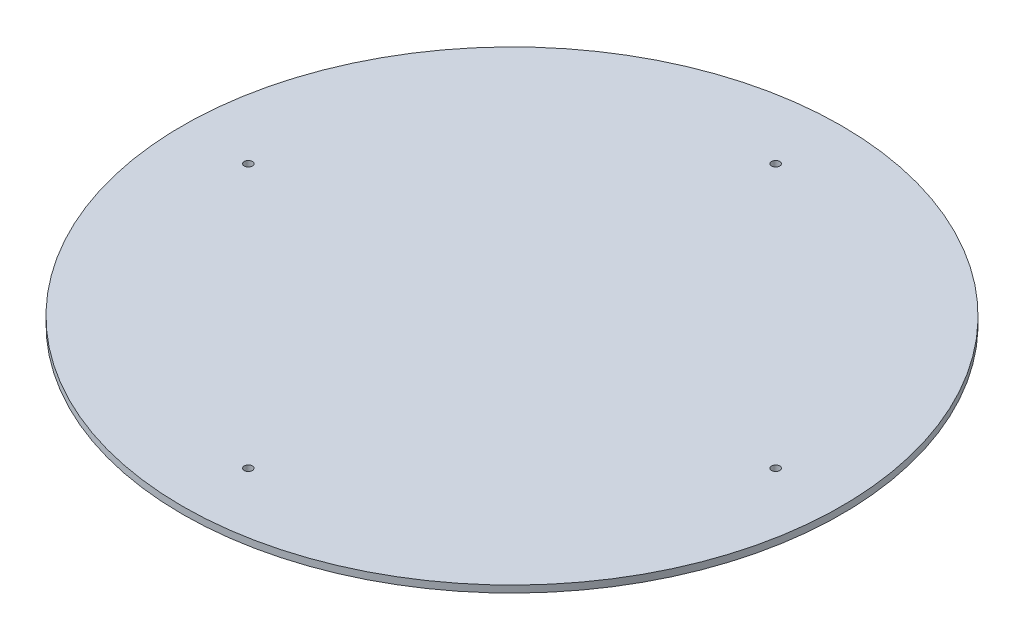
from build123d import *

# Parameters (mm, degrees)
TAPA_R                  = 285
SALIENTE_EXTRUIR1_DEPTH = 6
CROQUIS2_R              = 3.5
CORTAR_EXTRUIR4_DEPTH   = 7


with BuildPart() as part:
    # Tapa → Saliente-Extruir1 (new body)
    with BuildSketch(Plane(origin=(0, 0, 0), x_dir=(1, 0, 0), z_dir=(0, 1, 0))):
        Circle(TAPA_R)
    extrude(amount=SALIENTE_EXTRUIR1_DEPTH)

    # Croquis2 → Cortar-Extruir4 (cut, through all)
    with BuildSketch(Plane(origin=(0, 0, 0), x_dir=(1, 0, 0), z_dir=(0, 1, 0))):
        with Locations((228.035, 0)):
            Circle(CROQUIS2_R)
        with Locations((0, -228.035)):
            Circle(CROQUIS2_R)
        with Locations((-228.035, 0)):
            Circle(CROQUIS2_R)
        with Locations((0, 228.035)):
            Circle(CROQUIS2_R)
    extrude(amount=CORTAR_EXTRUIR4_DEPTH, mode=Mode.SUBTRACT)


solid = part.part
